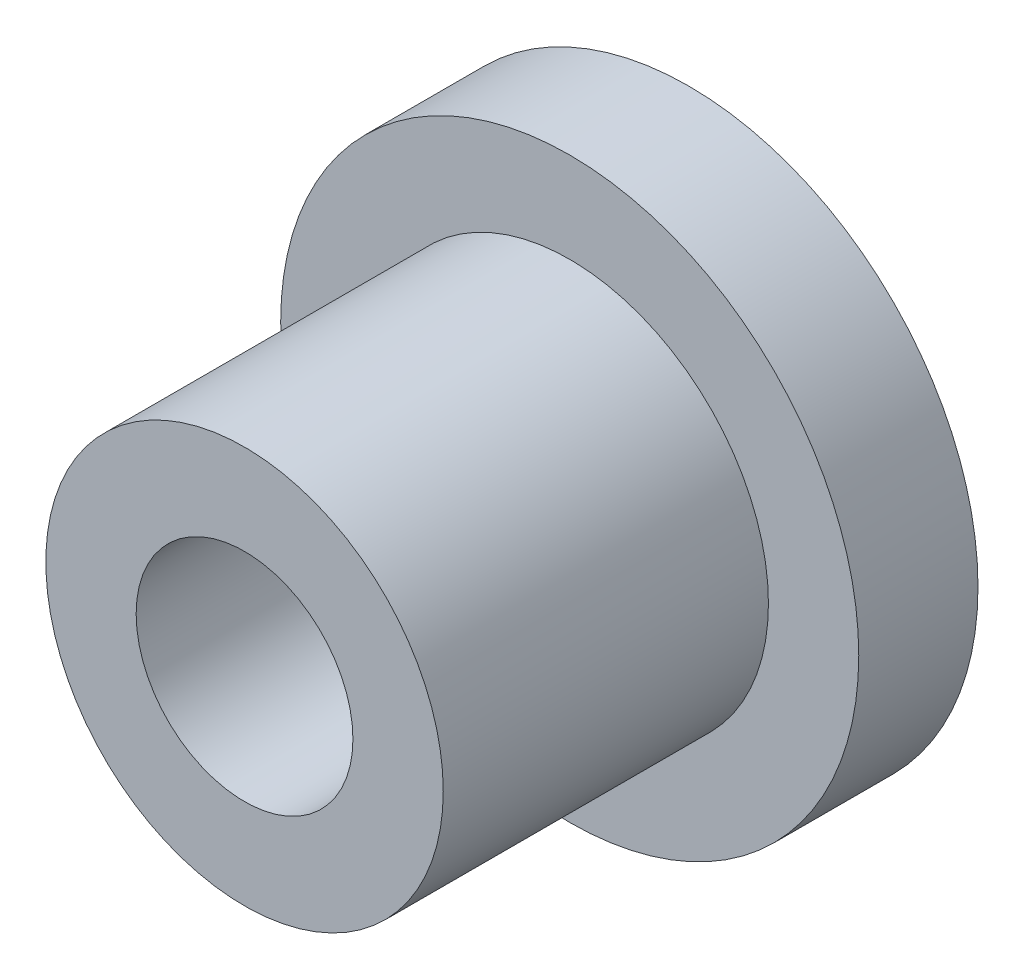
from build123d import *


with BuildPart() as part:
    # Sketch1 → Revolve1 (revolve)
    with BuildSketch(Plane(origin=(0, 0, 0), x_dir=(0, 0, -1), z_dir=(1, 0, 0))):
        Polygon((0, 3), (9, 3), (12.3, 6.3), (12.3, 8), (9, 8), (9, 5.5), (0, 5.5), align=None)
    revolve(axis=Axis((0, 0, 0), (0, 0, -1)))


solid = part.part
